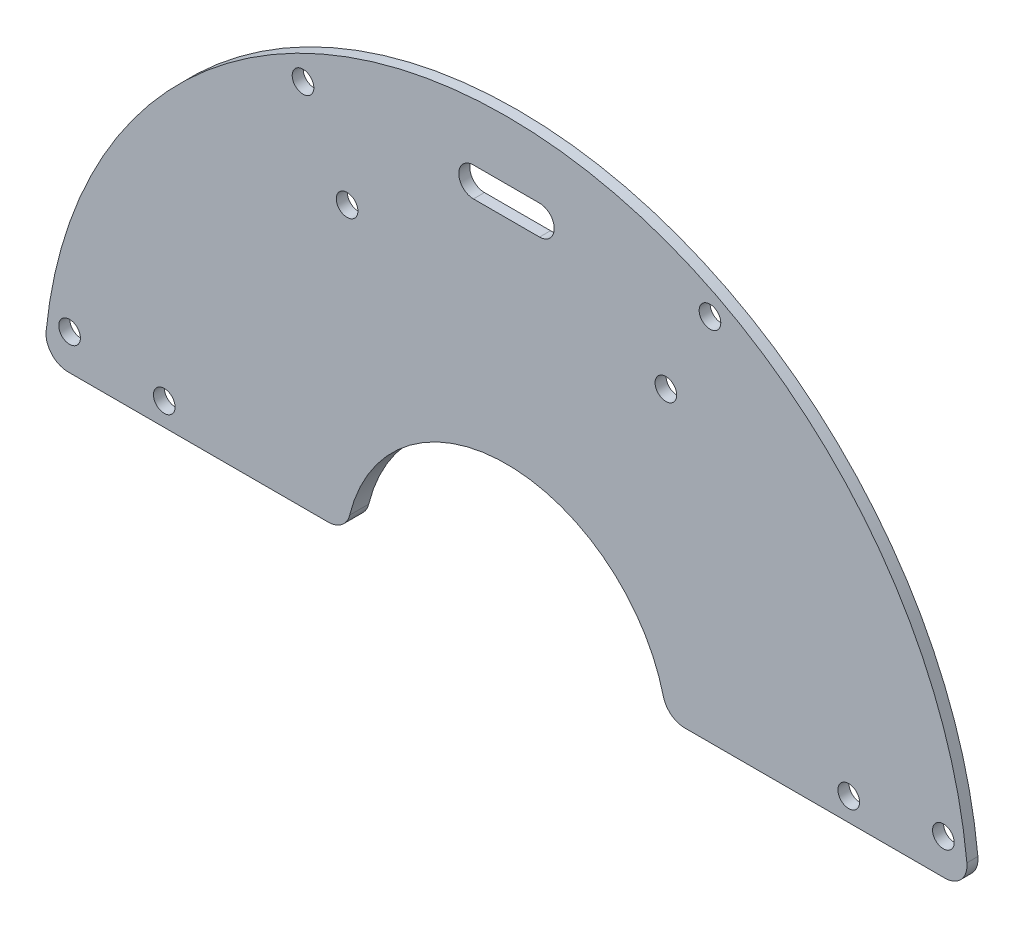
from build123d import *

# Parameters (mm, degrees)
SKETCH2_W                      = 198.000030872
SKETCH2_H                      = 103.32125718
CUT_EXTRUDE1_DEPTH             = 3.6
FILLET1_R                      = 5
FILLET2_R                      = 3
F_4_CLEARANCE_HOLE1_AT_2_COUNT = 2
F_4_CLEARANCE_HOLE1_AT_2_PITCH = 13
CIRPATTERN1_COUNT              = 4
CIRPATTERN1_ANGLE              = 165
CUT_EXTRUDE2_DEPTH             = 3.6000001


with BuildPart() as part:
    # Sketch1 → Revolve1 (revolve)
    with BuildSketch(Plane(origin=(0, 0, 0), x_dir=(0, 0, -1), z_dir=(1, 0, 0)), mode=Mode.PRIVATE) as revolve1_sk:
        Polygon((0, 22), (0, 63), (1.5, 63), (1.5, 35), (2.6, 32.5), (2.6, 22), align=None)
    revolve(revolve1_sk.sketch.rotate(Axis((0, 0, 0), (0, 0, -1)), 90), axis=Axis((0, 0, 0), (0, 0, -1)))  # turned: the seam where the file's is

    # Sketch2 → Cut-Extrude1 (cut, through all)
    with BuildSketch(Plane.XY):
        with Locations((-0.69062002, -48.66062859)):
            Rectangle(SKETCH2_W, SKETCH2_H)
    extrude(amount=-CUT_EXTRUDE1_DEPTH, mode=Mode.SUBTRACT)

    # Fillet1
    fillet1_edges = [part.edges().sort_by_distance(p)[0] for p in [
        (0, 32.5, -2.6),
        (0, 35, -1.5),
    ]]
    fillet(fillet1_edges, radius=FILLET1_R)

    # Fillet2
    fillet2_edges = [part.edges().sort_by_distance(p)[0] for p in [
        (-21.794494718, 3, -1.3),
        (-62.92853089, 3, -0.75),
        (21.794494718, 3, -1.3),
        (62.92853089, 3, -0.75),
    ]]
    fillet(fillet2_edges, radius=FILLET2_R)

    # Sketch3 → #4 Clearance Hole1 (revolve, cut)
    with BuildSketch(Plane(origin=(-59.486691682, 7.831571533, 0), x_dir=(0, -1, 0), z_dir=(1, 0, 0))):
        Polygon((0, 0), (0, 136.775187864), (1.4732, 135.89), (1.4732, 0), align=None)
    f_4_clearance_hole1 = revolve(axis=Axis((-59.486691682, 7.831571533, 6.35), (0, 0, -1)), mode=Mode.SUBTRACT)

    # #4 Clearance Hole1 at 2: #4 Clearance Hole1 ×2
    with Locations(*[Vector(0.991444861, -0.130526192, 0) * (i * F_4_CLEARANCE_HOLE1_AT_2_PITCH) for i in range(1, F_4_CLEARANCE_HOLE1_AT_2_COUNT)]):
        add(f_4_clearance_hole1, mode=Mode.SUBTRACT)

    # CirPattern1: #4 Clearance Hole1 ×4 about axis
    cirpattern1_axis = Axis((0, 0, 0), (0, 0, -1))
    for i in range(1, CIRPATTERN1_COUNT):
        add(f_4_clearance_hole1.rotate(cirpattern1_axis, i * CIRPATTERN1_ANGLE / (CIRPATTERN1_COUNT - 1)), mode=Mode.SUBTRACT)

    # CirPattern1 copy 1 sketch → CirPattern1 copy 1 (revolve, cut)
    with BuildSketch(Plane(origin=(-21.702184822, 41.689509159, 0), x_dir=(-0.819152044, -0.573576436, 0), z_dir=(0.573576436, -0.819152044, 0))):
        Polygon((0, 0), (0, 136.775187864), (1.4732, 135.89), (1.4732, 0), align=None)
    revolve(axis=Axis((-21.702184822, 41.689509159, 6.35), (0, 0, -1)), mode=Mode.SUBTRACT)

    # CirPattern1 copy 2 sketch → CirPattern1 copy 2 (revolve, cut)
    with BuildSketch(Plane(origin=(21.702184822, 41.689509159, 0), x_dir=(-0.939692621, 0.342020143, 0), z_dir=(-0.342020143, -0.939692621, 0))):
        Polygon((0, 0), (0, 136.775187864), (1.4732, 135.89), (1.4732, 0), align=None)
    revolve(axis=Axis((21.702184822, 41.689509159, 6.35), (0, 0, -1)), mode=Mode.SUBTRACT)

    # CirPattern1 copy 3 sketch → CirPattern1 copy 3 (revolve, cut)
    with BuildSketch(Plane(origin=(46.597908485, 6.134731034, 0), x_dir=(-0.258819045, 0.965925826, 0), z_dir=(-0.965925826, -0.258819045, 0))):
        Polygon((0, 0), (0, 136.775187864), (1.4732, 135.89), (1.4732, 0), align=None)
    revolve(axis=Axis((46.597908485, 6.134731034, 6.35), (0, 0, -1)), mode=Mode.SUBTRACT)

    # Sketch5 → Cut-Extrude2 (cut, through all)
    with BuildSketch(Plane.XY):
        with BuildLine():
            Line((-4.5, 55), (4.5, 55))
            ThreePointArc((4.5, 55), (6.5, 53), (4.5, 51))
            Line((4.5, 51), (-4.5, 51))
            ThreePointArc((-4.5, 51), (-6.5, 53), (-4.5, 55))
        make_face()
    extrude(amount=-CUT_EXTRUDE2_DEPTH, mode=Mode.SUBTRACT)


solid = part.part
